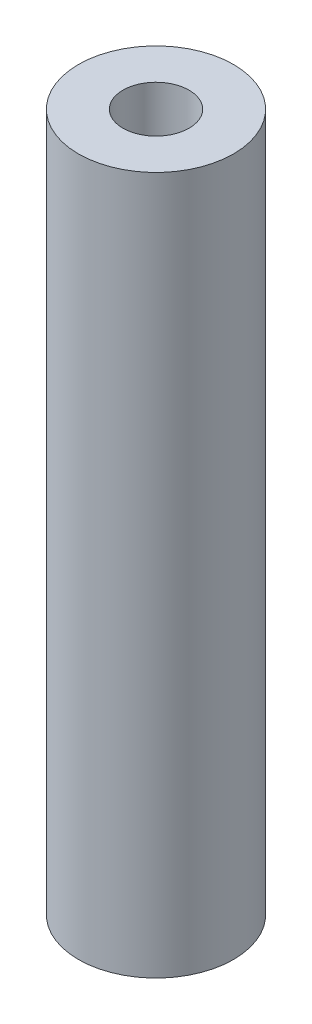
from build123d import *

# Parameters (mm, degrees)
SKETCH1_R                 = 3.175
BOSS_EXTRUDE1_DEPTH       = 28.575
TAP_DRILL_FOR_6_32_TAP1_D = 2.7051


with BuildPart() as part:
    # Sketch1 → Boss-Extrude1 (new body)
    with BuildSketch(Plane(origin=(0, 0, 0), x_dir=(1, 0, 0), z_dir=(0, 1, 0))):
        Circle(SKETCH1_R)
    extrude(amount=BOSS_EXTRUDE1_DEPTH)

    # Tap Drill for #6-32 Tap1 (through all)
    with Locations(Plane(origin=(0, 28.575, 0), x_dir=(1, 0, 0), z_dir=(0, 1, 0))):
        with Locations((0, 0)):
            Hole(TAP_DRILL_FOR_6_32_TAP1_D / 2)


solid = part.part
